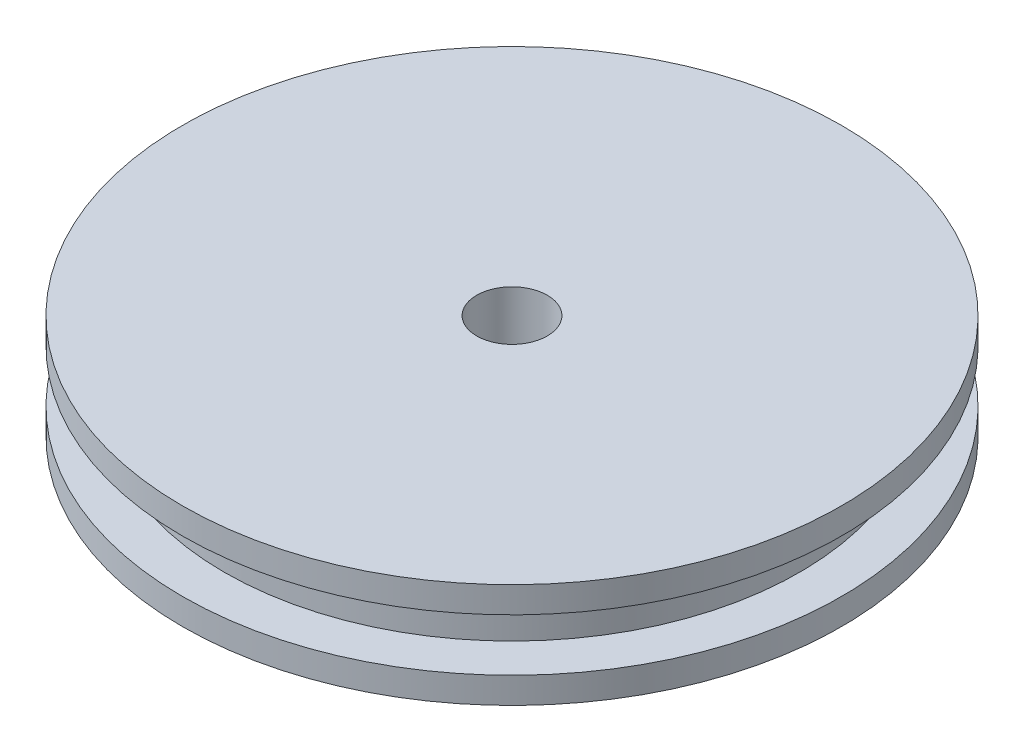
from build123d import *

# Parameters (mm, degrees)
ESBO_O1_R                = 6.3
RESSALTO_EXTRUS_O1_DEPTH = 0.5
ESBO_O10_R               = 5.5
RESSALTO_EXTRUS_O4_DEPTH = 1
ESBO_O11_R               = 6.3
RESSALTO_EXTRUS_O5_DEPTH = 0.5
CORTE_EXTRUS_O1_REACH    = 4
ESBO_O12_R               = 0.675


with BuildPart() as part:
    # Esboço1 → Ressalto-extrusão1 (new body)
    with BuildSketch(Plane(origin=(0, 0, 0), x_dir=(1, 0, 0), z_dir=(0, 1, 0))):
        Circle(ESBO_O1_R)
    extrude(amount=RESSALTO_EXTRUS_O1_DEPTH)

    # Esboço10 → Ressalto-extrusão4 (add)
    with BuildSketch(Plane(origin=(0, 0.5, 0), x_dir=(1, 0, 0), z_dir=(0, 1, 0))):
        Circle(ESBO_O10_R)
    extrude(amount=RESSALTO_EXTRUS_O4_DEPTH)

    # Esboço11 → Ressalto-extrusão5 (add)
    with BuildSketch(Plane(origin=(0, 1.5, 0), x_dir=(1, 0, 0), z_dir=(0, 1, 0))):
        Circle(ESBO_O11_R)
    extrude(amount=RESSALTO_EXTRUS_O5_DEPTH)

    # Esboço12 → Corte-extrusão1 (cut, up to next)
    with BuildSketch(Plane.XZ, mode=Mode.PRIVATE) as corte_extrus_o1_sk1:
        Circle(ESBO_O12_R)
    corte_extrus_o1_tool1 = extrude(corte_extrus_o1_sk1.sketch, amount=-CORTE_EXTRUS_O1_REACH, mode=Mode.PRIVATE) & part.part
    add(corte_extrus_o1_tool1.solids().sort_by_distance((0, 0, 0))[0], mode=Mode.SUBTRACT)


solid = part.part
